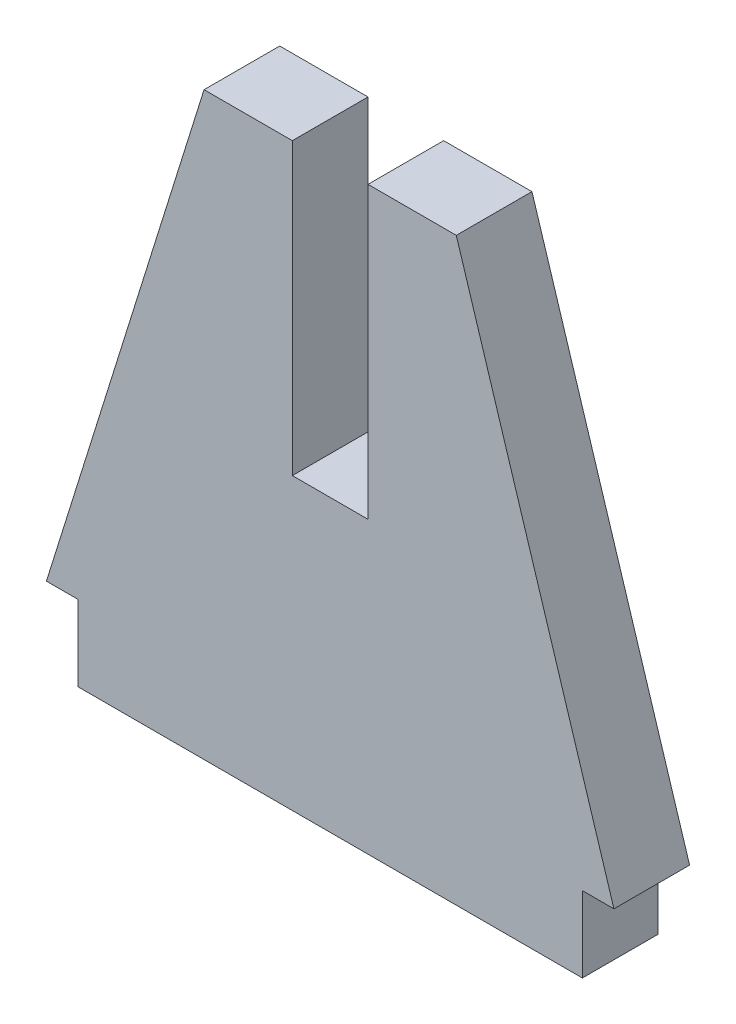
from build123d import *

# Parameters (mm, degrees)
BOSS_EXTRUDE1_DEPTH = 3
SKETCH2_W           = 6
SKETCH2_H           = 23
CUT_EXTRUDE1_DEPTH  = 7


with BuildPart() as part:
    # Sketch1 → Boss-Extrude1 (new body, symmetric)
    with BuildSketch(Plane.XY):
        Polygon((-20, 0), (20, 0), (20, 6), (22.5, 6), (10, 46), (-10, 46), (-22.5, 6), (-20, 6), align=None)
    extrude(amount=BOSS_EXTRUDE1_DEPTH, both=True)

    # Sketch2 → Cut-Extrude1 (cut, through all)
    with BuildSketch(Plane.XY.offset(3)):
        with Locations((0, 34.5)):
            Rectangle(SKETCH2_W, SKETCH2_H)
    extrude(amount=-CUT_EXTRUDE1_DEPTH, mode=Mode.SUBTRACT)


solid = part.part
